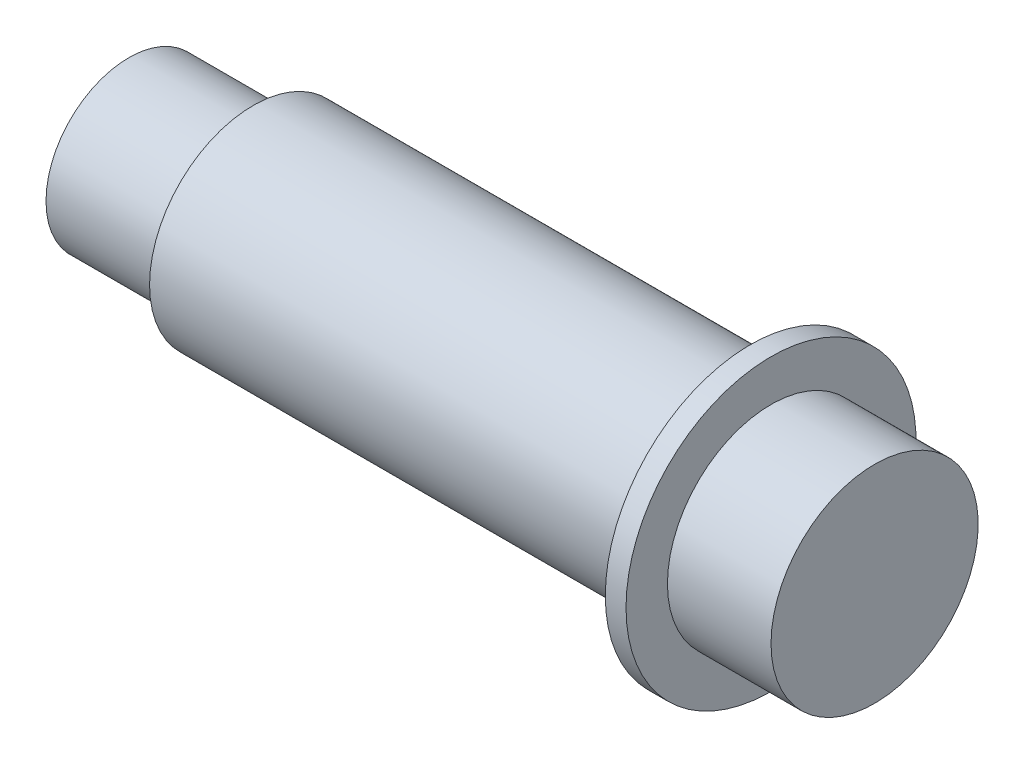
from build123d import *


with BuildPart() as part:
    # Skizze1 → Rotation1 (revolve)
    with BuildSketch(Plane.XY):
        Polygon((0, 0), (0, 2), (3, 2), (3, 2.5), (15, 2.5), (15, 3.5), (15.5, 3.5), (15.5, 2.5), (18, 2.5), (18, 0), align=None)
    revolve(axis=Axis((0, 0, 0), (1, 0, 0)))


solid = part.part
